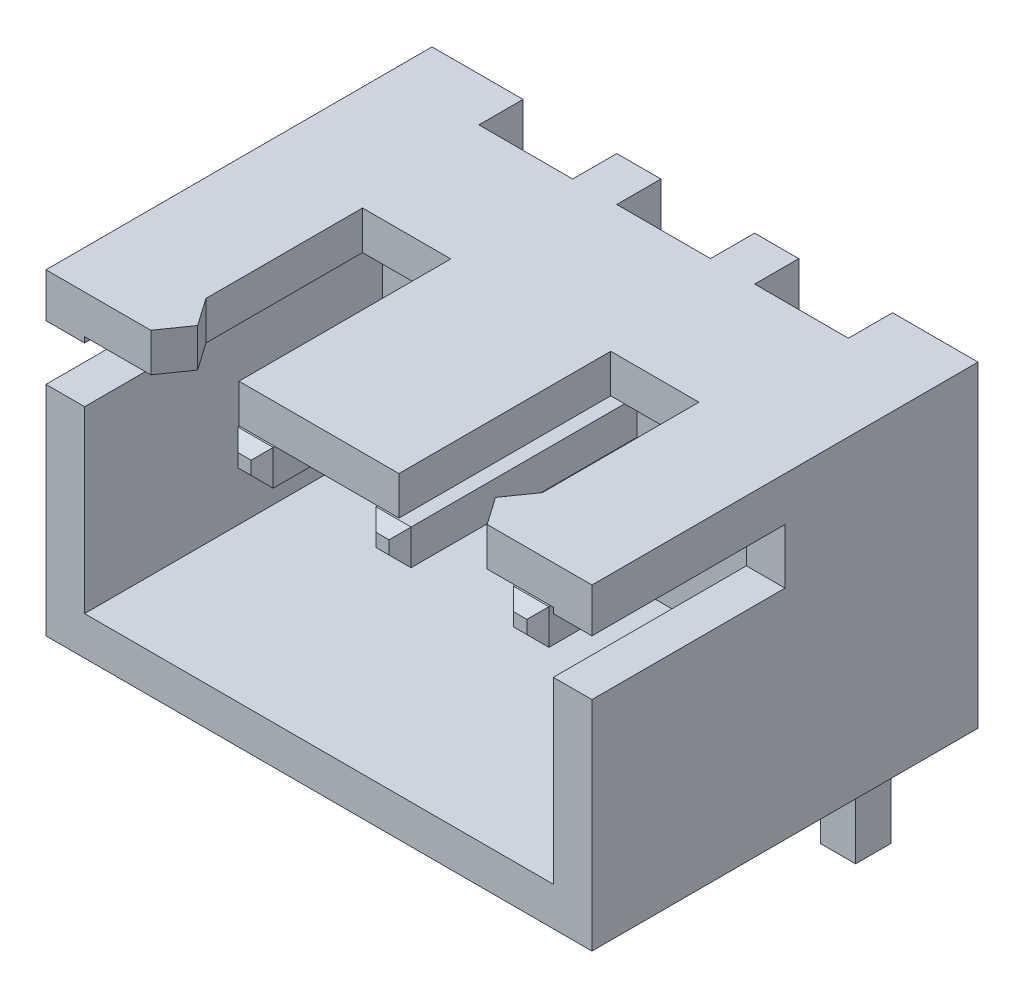
from build123d import *

# Parameters (mm, degrees)
SKETCH1_W                 = 9.9
SKETCH1_H                 = 7
BOSS_EXTRUDE1_DEPTH       = 2.875
SHELL1_T                  = -0.7
SHELL1_THICKNESS_2_FACE_W = 8.5
SHELL1_THICKNESS_2_FACE_H = 4.35
SHELL1_THICKNESS_2_DEPTH  = 0.9
SKETCH2_W                 = 3.5
SKETCH2_H                 = 1
CUT_EXTRUDE1_DEPTH        = 7.709554754
CUT_EXTRUDE1_DEPTH_BACK   = 7.709554754
CUT_EXTRUDE2_DEPTH        = 7.709554754
BOSS_EXTRUDE2_START       = 2.175
SKETCH4_W                 = 2.9
SKETCH4_H                 = 3.84
BOSS_EXTRUDE2_DEPTH       = 0.7
SKETCH5_W                 = 0.8
SKETCH5_H                 = 5.75
CUT_EXTRUDE3_DEPTH        = 0.85
LPATTERN1_COUNT           = 3
LPATTERN1_PITCH           = 2.5
BOSS_EXTRUDE3_DEPTH       = 0.32
FILLET1_R                 = 1
FILLET2_R                 = 0.34
CHAMFER1_SIZE             = 0.2
LPATTERN2_COUNT           = 3
LPATTERN2_PITCH           = 2.5


with BuildPart() as part:
    # Sketch1 → Boss-Extrude1 (new, symmetric)
    with BuildSketch(Plane(origin=(0, 0, 0), x_dir=(1, 0, 0), z_dir=(0, 1, 0))):
        Rectangle(SKETCH1_W, SKETCH1_H)
    extrude(amount=BOSS_EXTRUDE1_DEPTH, both=True)

    # Shell1
    shell1_openings = [part.faces().sort_by_distance(p)[0] for p in [
        (0, 0, 3.5),
    ]]
    offset(amount=SHELL1_T, openings=shell1_openings, kind=Kind.INTERSECTION)

    # Shell1 thickness 2 face (on inner face of the shell) → Shell1 thickness 2 (add)
    with BuildSketch(Plane(origin=(0, 0, -2.8), x_dir=(-1, 0, 0), z_dir=(0, 0, -1))):
        Rectangle(SHELL1_THICKNESS_2_FACE_W, SHELL1_THICKNESS_2_FACE_H)
    extrude(amount=-SHELL1_THICKNESS_2_DEPTH)

    # Sketch2 → Cut-Extrude1 (cut, two sides)
    with BuildSketch(Plane(origin=(0, 0, 0), x_dir=(0, 0, -1), z_dir=(1, 0, 0))) as cut_extrude1_sk:
        with Locations((-1.75, 1.575)):
            Rectangle(SKETCH2_W, SKETCH2_H)
    extrude(amount=CUT_EXTRUDE1_DEPTH, mode=Mode.SUBTRACT)
    extrude(cut_extrude1_sk.sketch, amount=-CUT_EXTRUDE1_DEPTH_BACK, mode=Mode.SUBTRACT)

    # Sketch3 → Cut-Extrude2 (cut, through all)
    with BuildSketch(Plane(origin=(0, 0, 0), x_dir=(1, 0, 0), z_dir=(0, 1, 0))):
        Polygon((-3.05, -3.5), (-2.7, -3), (-3.05, -2.5), (-3.05, 0.34), (3.05, 0.34), (3.05, -2.5), (2.7, -3), (3.05, -3.5), align=None)
    extrude(amount=CUT_EXTRUDE2_DEPTH, mode=Mode.SUBTRACT)

    # Sketch4 → Boss-Extrude2 (add)
    with BuildSketch(Plane(origin=(0, 0, 0), x_dir=(1, 0, 0), z_dir=(0, 1, 0)).offset(BOSS_EXTRUDE2_START)):
        with Locations((0, -1.58)):
            Rectangle(SKETCH4_W, SKETCH4_H)
    extrude(amount=BOSS_EXTRUDE2_DEPTH)

    # Sketch5 → Cut-Extrude3 (cut, symmetric)
    with BuildSketch(Plane(origin=(2.55, 0, 0), x_dir=(0, 0, -1), z_dir=(1, 0, 0))):
        with Locations((3.1, 0)):
            Rectangle(SKETCH5_W, SKETCH5_H)
    cut_extrude3 = extrude(amount=CUT_EXTRUDE3_DEPTH, both=True, mode=Mode.SUBTRACT)

    # LPattern1: Cut-Extrude3 ×3
    with Locations(*[(-i * LPATTERN1_PITCH, 0, 0) for i in range(1, LPATTERN1_COUNT)]):
        add(cut_extrude3, mode=Mode.SUBTRACT)


with BuildPart() as body_2:
    # Sketch6 → Boss-Extrude3 (new, symmetric)
    with BuildSketch(Plane(origin=(2.55, 0, 0), x_dir=(0, 0, -1), z_dir=(1, 0, 0))):
        Polygon((-2.4, 0.845), (4, 0.845), (4, -6.175), (3.36, -6.175), (3.36, 0.205), (-2.4, 0.205), align=None)
    extrude(amount=BOSS_EXTRUDE3_DEPTH, both=True)

    # Fillet1
    fillet1_edges = [body_2.edges().sort_by_distance(p)[0] for p in [
        (2.55, 0.845, -4),
    ]]
    fillet(fillet1_edges, radius=FILLET1_R)

    # Fillet2
    fillet2_edges = [body_2.edges().sort_by_distance(p)[0] for p in [
        (2.55, 0.205, -3.36),
    ]]
    fillet(fillet2_edges, radius=FILLET2_R)

    # Chamfer1
    chamfer1_edges = [body_2.edges().sort_by_distance(p)[0] for p in [
        (2.55, 0.845, 2.4),
        (2.55, -6.175, -4),
        (2.55, -6.175, -3.36),
        (2.55, 0.205, 2.4),
        (2.87, -6.175, -3.68),
        (2.87, 0.525, 2.4),
        (2.23, -6.175, -3.68),
        (2.23, 0.525, 2.4),
    ]]
    chamfer(chamfer1_edges, length=CHAMFER1_SIZE)


with BuildPart() as lpattern2_1:
    # LPattern2: pattern copy
    add(body_2.part.moved(Location(Vector(-1, 0, 0) * (1 * LPATTERN2_PITCH))))


with BuildPart() as lpattern2_2:
    # LPattern2: pattern copy
    add(body_2.part.moved(Location(Vector(-1, 0, 0) * (2 * LPATTERN2_PITCH))))


solid = Compound([part.part, body_2.part, lpattern2_1.part, lpattern2_2.part])
